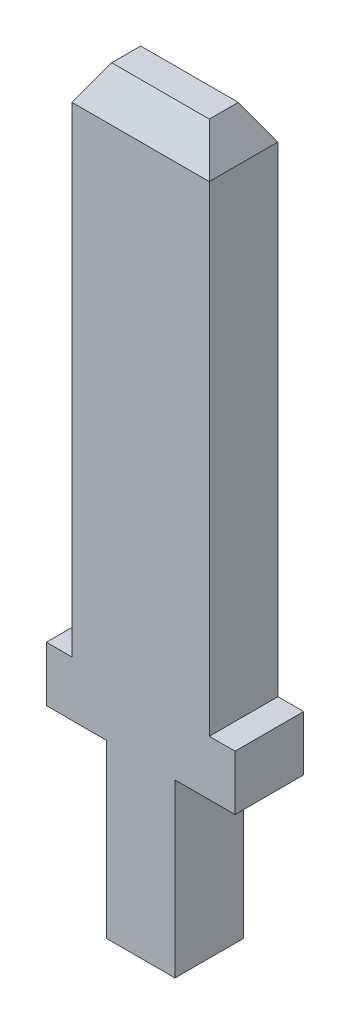
from build123d import *

# Parameters (mm, degrees)
EXTRUDE_1_DEPTH        = 1
CHAMFER_1_SIZE         = 1
CHAMFER_1_SIZE2        = 0.577350269
CHAMFER_1_PART_2_SIZE  = 1
CHAMFER_1_PART_2_SIZE2 = 0.577350269
CHAMFER_1_PART_3_SIZE  = 1
CHAMFER_1_PART_3_SIZE2 = 0.577350269
CHAMFER_1_PART_4_SIZE  = 1
CHAMFER_1_PART_4_SIZE2 = 0.577350269


with BuildPart() as part:
    # Эскиз1 → Бобышка-Вытянуть1 (new body, symmetric)
    with BuildSketch(Plane.XY):
        Polygon((1, 0), (-1, 0), (-1, 5), (-2.75, 5), (-2.75, 6.6), (-2, 6.6), (-2, 21.6), (2, 21.6), (2, 6.6), (2.75, 6.6), (2.75, 5), (1, 5), align=None)
    extrude(amount=EXTRUDE_1_DEPTH, both=True)

    # Фаска1
    chamfer_1_edges = [part.edges().sort_by_distance(p)[0] for p in [
        (0, 21.6, -1),
    ]]
    chamfer_1_side = [part.faces().sort_by_distance(p)[0] for p in [
        (0, 11.701015228, -1),
    ]]
    chamfer(chamfer_1_edges, length=CHAMFER_1_SIZE, length2=CHAMFER_1_SIZE2, reference=chamfer_1_side[0])

    # Фаска1 part 2
    chamfer_1_part_2_edges = [part.edges().sort_by_distance(p)[0] for p in [
        (-2, 21.6, 0),
    ]]
    chamfer_1_part_2_side = [part.faces().sort_by_distance(p)[0] for p in [
        (-2, 14.1, 0),
    ]]
    chamfer(chamfer_1_part_2_edges, length=CHAMFER_1_PART_2_SIZE, length2=CHAMFER_1_PART_2_SIZE2, reference=chamfer_1_part_2_side[0])

    # Фаска1 part 3
    chamfer_1_part_3_edges = [part.edges().sort_by_distance(p)[0] for p in [
        (2, 21.6, 0),
    ]]
    chamfer_1_part_3_side = [part.faces().sort_by_distance(p)[0] for p in [
        (2, 14.1, 0),
    ]]
    chamfer(chamfer_1_part_3_edges, length=CHAMFER_1_PART_3_SIZE, length2=CHAMFER_1_PART_3_SIZE2, reference=chamfer_1_part_3_side[0])

    # Фаска1 part 4
    chamfer_1_part_4_edges = [part.edges().sort_by_distance(p)[0] for p in [
        (0, 21.6, 1),
    ]]
    chamfer_1_part_4_side = [part.faces().sort_by_distance(p)[0] for p in [
        (0, 11.701015228, 1),
    ]]
    chamfer(chamfer_1_part_4_edges, length=CHAMFER_1_PART_4_SIZE, length2=CHAMFER_1_PART_4_SIZE2, reference=chamfer_1_part_4_side[0])


solid = part.part
